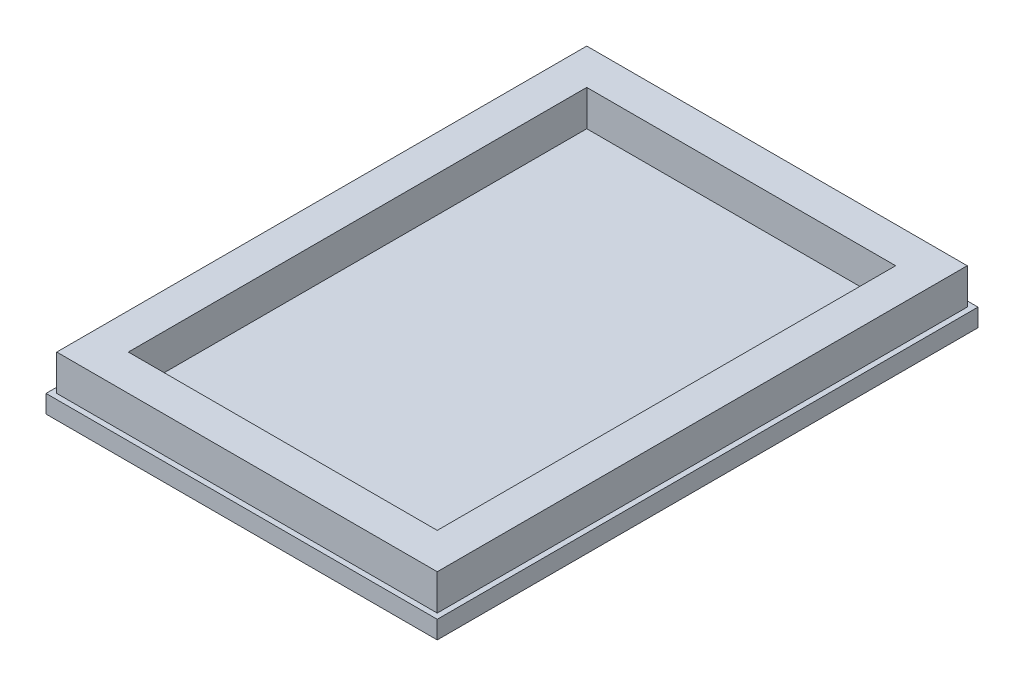
from build123d import *

# Parameters (mm, degrees)
SKETCH1_W           = 21.85
SKETCH1_H           = 30.2
BOSS_EXTRUDE1_DEPTH = 1
SKETCH2_W           = 21.25
SKETCH2_H           = 29.6
SKETCH2_W_2         = 17.25
SKETCH2_H_2         = 25.6
BOSS_EXTRUDE2_DEPTH = 2


with BuildPart() as part:
    # Sketch1 → Boss-Extrude1 (new body)
    with BuildSketch(Plane(origin=(0, 0, 0), x_dir=(1, 0, 0), z_dir=(0, 1, 0))):
        Rectangle(SKETCH1_W, SKETCH1_H)
    extrude(amount=BOSS_EXTRUDE1_DEPTH)

    # Sketch2 → Boss-Extrude2 (add)
    with BuildSketch(Plane(origin=(0, 1, 0), x_dir=(1, 0, 0), z_dir=(0, 1, 0))):
        Rectangle(SKETCH2_W, SKETCH2_H)
        Rectangle(SKETCH2_W_2, SKETCH2_H_2, mode=Mode.SUBTRACT)
    extrude(amount=BOSS_EXTRUDE2_DEPTH)


solid = part.part
